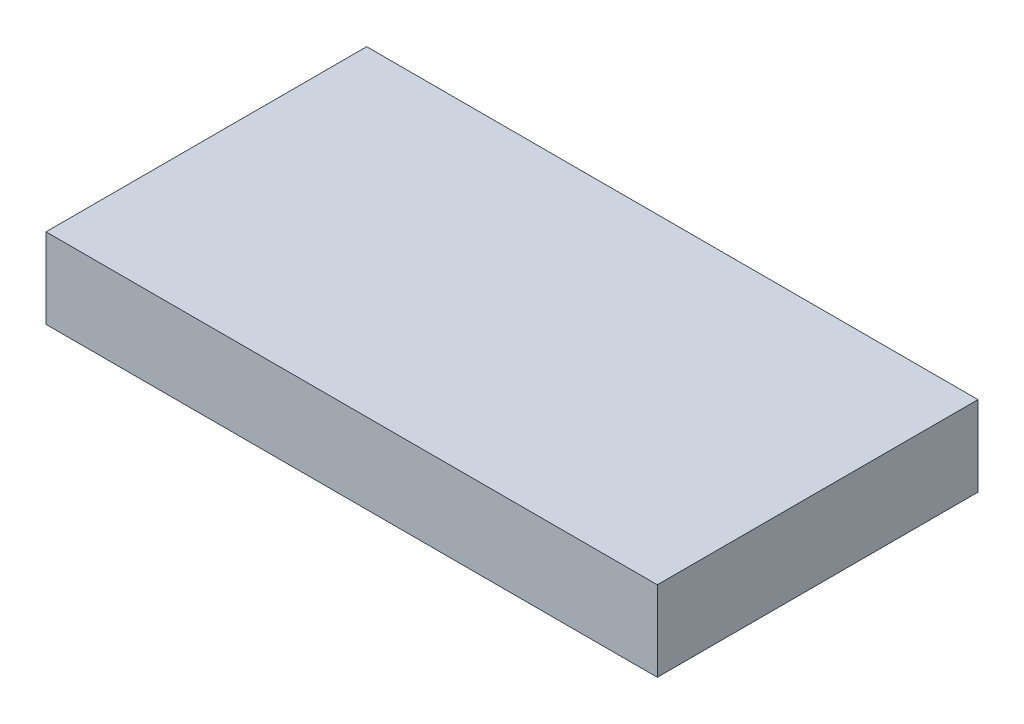
from build123d import *

# Parameters (mm, degrees)
SKETCH1_W           = 193.675
SKETCH1_H           = 101.6
BOSS_EXTRUDE1_DEPTH = 12.7


with BuildPart() as part:
    # Sketch1 → Boss-Extrude1 (new body, symmetric)
    with BuildSketch(Plane(origin=(0, 0, 0), x_dir=(1, 0, 0), z_dir=(0, 1, 0))):
        Rectangle(SKETCH1_W, SKETCH1_H)
    extrude(amount=BOSS_EXTRUDE1_DEPTH, both=True)


solid = part.part
